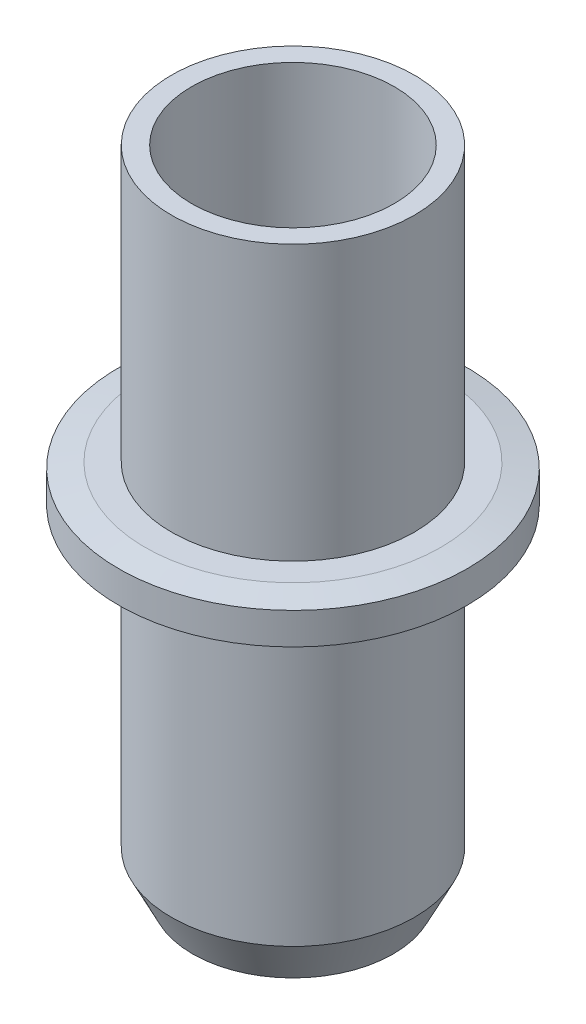
from build123d import *


with BuildPart() as part:
    # Sketch1 → 5.63 mm bottom to pen tip (revolve)
    with BuildSketch(Plane.XY):
        Polygon((0, 0), (2.375, 0), (3.2, 5.5), (3.2, 6.5), (4.75, 6.5), (5.75, 8.5), (5.75, 22.3), (7, 22.3), (8.25, 22.55), (8.25, 24.05), (7, 24.3), (5.75, 24.3), (5.75, 37.3), (0, 37.3), align=None)
    revolve(axis=Axis((0, -143.950460456, 0), (0, 1, 0)))

    # Sketch2 → Cut-Revolve1 (revolve, cut)
    with BuildSketch(Plane.XY):
        Polygon((0, -5.63), (0.39, -5.63), (0.39, -2.03), (1.1, -2.03), (1.65, 0.35), (2.4, 0.35), (4.185, 10.48), (4.8, 10.48), (4.8, 42.48), (5.967443991, 42.48), (5.967443991, 45.051498483), (0, 45.051498483), align=None)
    revolve(axis=Axis((0, -1000, 0), (0, 1, 0)), mode=Mode.SUBTRACT)


with BuildPart() as body_2:
    # of the pieces the cut leaves, the one that is kept (cut_revolve1_keep)
    add(part.part.solids().sort_by_distance((4.75, 6.5, 0))[0])


solid = body_2.part
